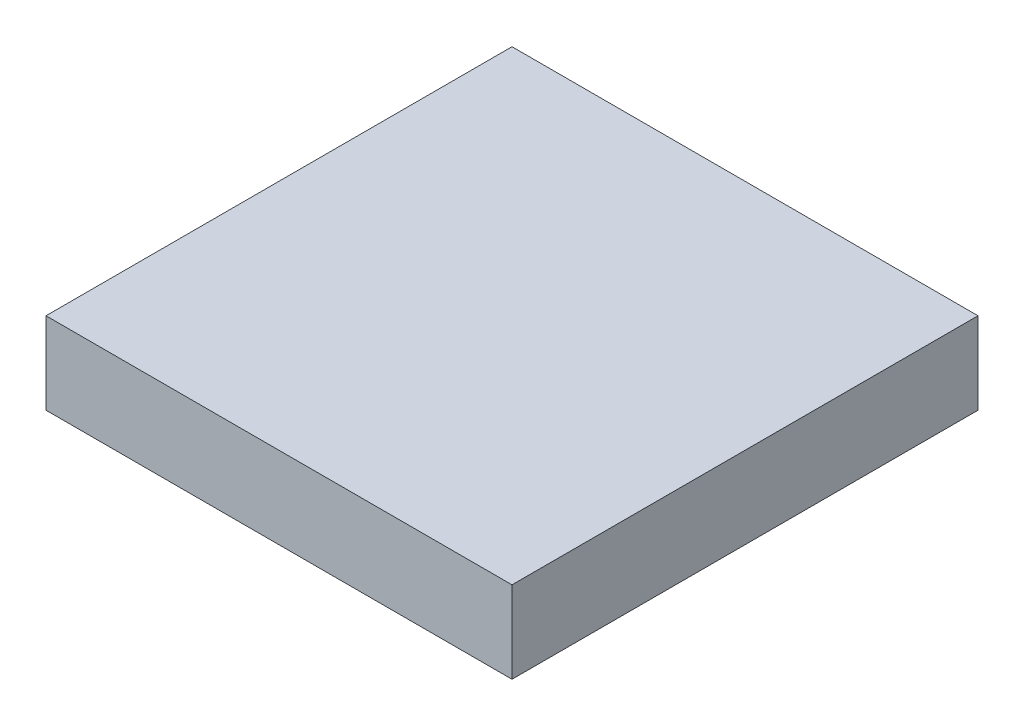
from build123d import *

# Parameters (mm, degrees)
SKETCH1_W           = 25.4
SKETCH1_H           = 25.4
BOSS_EXTRUDE1_DEPTH = 4.46


with BuildPart() as part:
    # Sketch1 → Boss-Extrude1 (new body)
    with BuildSketch(Plane(origin=(0, 0, 0), x_dir=(1, 0, 0), z_dir=(0, 1, 0))):
        with Locations((12.7, -12.7)):
            Rectangle(SKETCH1_W, SKETCH1_H)
    extrude(amount=BOSS_EXTRUDE1_DEPTH)


solid = part.part
